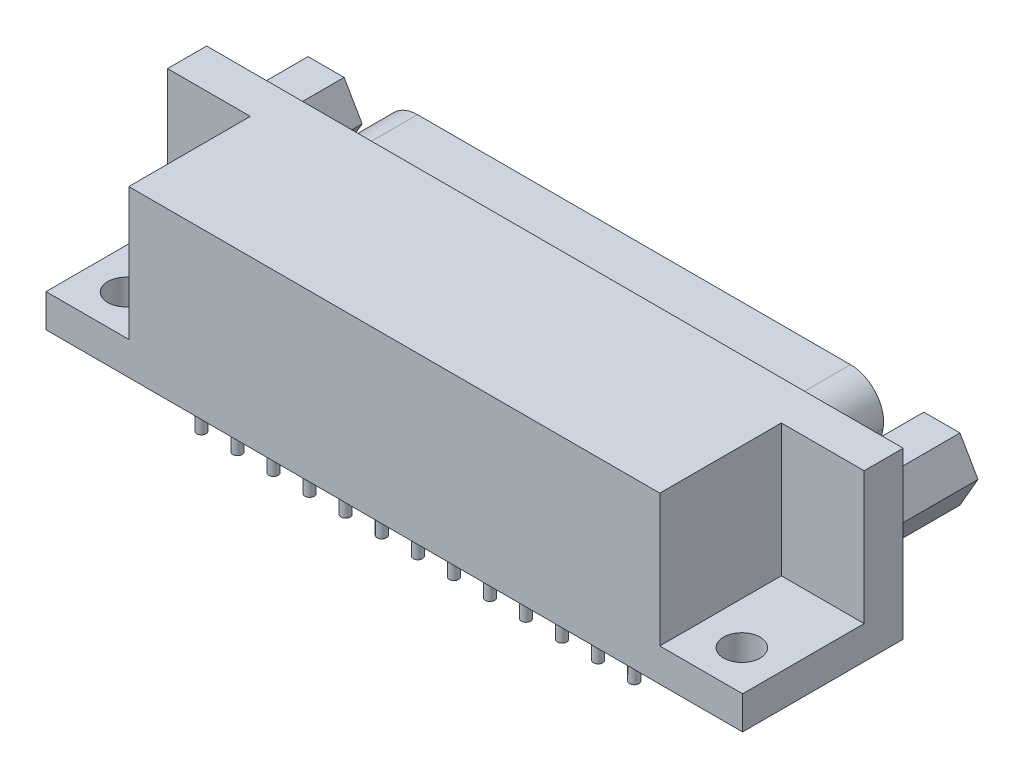
from build123d import *

# Parameters (mm, degrees)
SKETCH1_W           = 53.47
SKETCH1_H           = 12.33
BASE_EXTRUDE_DEPTH  = 12.7
BOSS_EXTRUDE1_DEPTH = 6.07
SKETCH4_R           = 0.5
CUT_EXTRUDE1_DEPTH  = 5.08
SKETCH5_R           = 0.5
CUT_EXTRUDE2_DEPTH  = 5.08
SKETCH6_R           = 0.3556
BOSS_EXTRUDE2_DEPTH = 2.54
LPATTERN1_COUNT     = 13
LPATTERN1_PITCH     = 2.7686
LPATTERN2_COUNT     = 13
LPATTERN2_PITCH     = 2.7686
LPATTERN3_COUNT     = 12
LPATTERN3_PITCH     = 2.7686
SKETCH7_R           = 0.3556
BOSS_EXTRUDE3_DEPTH = 2.54
LPATTERN4_COUNT     = 12
LPATTERN4_PITCH     = 2.7686
SKETCH12_R          = 1.304277921
BOSS_EXTRUDE4_DEPTH = 6.07
SKETCH9_W           = 6.35508
SKETCH9_H           = 10.16
CUT_EXTRUDE3_DEPTH  = 9.33
SKETCH11_R          = 1.4
CUT_EXTRUDE4_DEPTH  = 6.08
CHAMFER1_SIZE       = 0.4


with BuildPart() as part:
    # Sketch1 → Base-Extrude (new body)
    with BuildSketch(Plane(origin=(0, 0, 0), x_dir=(1, 0, 0), z_dir=(0, 1, 0))):
        with Locations((16.575, 4.395)):
            Rectangle(SKETCH1_W, SKETCH1_H)
    extrude(amount=BASE_EXTRUDE_DEPTH)

    # Sketch2 → Boss-Extrude1 (add)
    with BuildSketch(Plane(origin=(0, 0, -10.56), x_dir=(-1, 0, 0), z_dir=(0, 0, -1))):
        with BuildLine():
            Line((-32.654431338, 2.286), (-0.495568662, 2.286))
            ThreePointArc((-0.495568662, 2.286), (1.120925043, 2.8667787), (1.998186376, 4.34352118))
            Line((1.998186376, 4.34352118), (2.538755038, 7.13752118))
            ThreePointArc((2.538755038, 7.13752118), (2.0042213, 9.236493705), (0.045, 10.16))
            Line((0.045, 10.16), (-33.195, 10.16))
            ThreePointArc((-33.195, 10.16), (-35.1542213, 9.236493705), (-35.688755038, 7.13752118))
            Line((-35.688755038, 7.13752118), (-35.148186376, 4.34352118))
            ThreePointArc((-35.148186376, 4.34352118), (-34.270925043, 2.8667787), (-32.654431338, 2.286))
        make_face()
    extrude(amount=BOSS_EXTRUDE1_DEPTH)

    # Sketch4 → Cut-Extrude1 (cut)
    with BuildSketch(Plane(origin=(0, 0, -16.63), x_dir=(-1, 0, 0), z_dir=(0, 0, -1))):
        with Locations((0, 7.62)):
            Circle(SKETCH4_R)
    cut_extrude1 = extrude(amount=-CUT_EXTRUDE1_DEPTH, mode=Mode.SUBTRACT)

    # Sketch5 → Cut-Extrude2 (cut)
    with BuildSketch(Plane(origin=(0, 0, -16.63), x_dir=(-1, 0, 0), z_dir=(0, 0, -1))):
        with Locations((-1.397, 5.08)):
            Circle(SKETCH5_R)
    cut_extrude2 = extrude(amount=-CUT_EXTRUDE2_DEPTH, mode=Mode.SUBTRACT)

    # Sketch6 → Boss-Extrude2 (add)
    with BuildSketch(Plane.XZ):
        Circle(SKETCH6_R)
    boss_extrude2 = extrude(amount=BOSS_EXTRUDE2_DEPTH)

    # LPattern1: Boss-Extrude2 ×13
    with Locations(*[(i * LPATTERN1_PITCH, 0, 0) for i in range(1, LPATTERN1_COUNT)]):
        add(boss_extrude2)

    # LPattern2: Cut-Extrude1 ×13
    with Locations(*[(i * LPATTERN2_PITCH, 0, 0) for i in range(1, LPATTERN2_COUNT)]):
        add(cut_extrude1, mode=Mode.SUBTRACT)

    # LPattern3: Cut-Extrude2 ×12
    with Locations(*[(i * LPATTERN3_PITCH, 0, 0) for i in range(1, LPATTERN3_COUNT)]):
        add(cut_extrude2, mode=Mode.SUBTRACT)

    # Sketch7 → Boss-Extrude3 (add)
    with BuildSketch(Plane.XZ):
        with Locations((1.397, -2.54)):
            Circle(SKETCH7_R)
    boss_extrude3 = extrude(amount=BOSS_EXTRUDE3_DEPTH)

    # LPattern4: Boss-Extrude3 ×12
    with Locations(*[(i * LPATTERN4_PITCH, 0, 0) for i in range(1, LPATTERN4_COUNT)]):
        add(boss_extrude3)

    # Sketch12 → Boss-Extrude4 (add)
    with BuildSketch(Plane(origin=(0, 0, -10.56), x_dir=(-1, 0, 0), z_dir=(0, 0, -1))):
        Polygon((-41.595, 9.82), (-42.98, 7.421109632), (-41.595, 5.022219263), (-38.825, 5.022219263), (-37.44, 7.421109632), (-38.825, 9.82), align=None)
        with Locations((-40.21, 7.421109632)):
            Circle(SKETCH12_R, mode=Mode.SUBTRACT)
    boss_extrude4 = extrude(amount=BOSS_EXTRUDE4_DEPTH)

    # Sketch9 → Cut-Extrude3 (cut)
    with BuildSketch(Plane.XY.offset(1.77)):
        with Locations((-6.98246, 7.62)):
            Rectangle(SKETCH9_W, SKETCH9_H)
    cut_extrude3 = extrude(amount=-CUT_EXTRUDE3_DEPTH, mode=Mode.SUBTRACT)

    # Sketch11 → Cut-Extrude4 (cut, through all)
    with BuildSketch(Plane(origin=(0, 2.54, 0), x_dir=(-1, 0, 0), z_dir=(0, 1, 0))):
        with Locations((7.06, -1.27)):
            Circle(SKETCH11_R)
    cut_extrude4 = extrude(amount=-CUT_EXTRUDE4_DEPTH, mode=Mode.SUBTRACT)

    # Mirror1: Boss-Extrude4, Cut-Extrude3, Cut-Extrude4 across plane
    add(boss_extrude4.mirror(Plane(origin=(16.575, 0, 0), x_dir=(0, 0, 1), z_dir=(1, 0, 0))))
    add(cut_extrude3.mirror(Plane(origin=(16.575, 0, 0), x_dir=(0, 0, 1), z_dir=(1, 0, 0))), mode=Mode.SUBTRACT)
    add(cut_extrude4.mirror(Plane(origin=(16.575, 0, 0), x_dir=(0, 0, 1), z_dir=(1, 0, 0))), mode=Mode.SUBTRACT)

    # Chamfer1
    chamfer1_edges = [part.edges().sort_by_distance(p)[0] for p in [
        (19.8802, 7.62, -16.63),
        (22.6488, 7.62, -16.63),
        (25.4174, 7.62, -16.63),
        (28.186, 7.62, -16.63),
        (30.9546, 7.62, -16.63),
        (33.7232, 7.62, -16.63),
        (4.6656, 5.08, -16.63),
        (7.4342, 5.08, -16.63),
        (10.2028, 5.08, -16.63),
        (12.9714, 5.08, -16.63),
        (15.74, 5.08, -16.63),
        (18.5086, 5.08, -16.63),
        (21.2772, 5.08, -16.63),
        (24.0458, 5.08, -16.63),
        (26.8144, 5.08, -16.63),
        (29.583, 5.08, -16.63),
        (32.3516, 5.08, -16.63),
        (0.5, 7.62, -16.63),
        (1.897, 5.08, -16.63),
        (3.2686, 7.62, -16.63),
        (6.0372, 7.62, -16.63),
        (8.8058, 7.62, -16.63),
        (11.5744, 7.62, -16.63),
        (14.343, 7.62, -16.63),
        (17.1116, 7.62, -16.63),
    ]]
    chamfer(chamfer1_edges, length=CHAMFER1_SIZE)


solid = part.part
